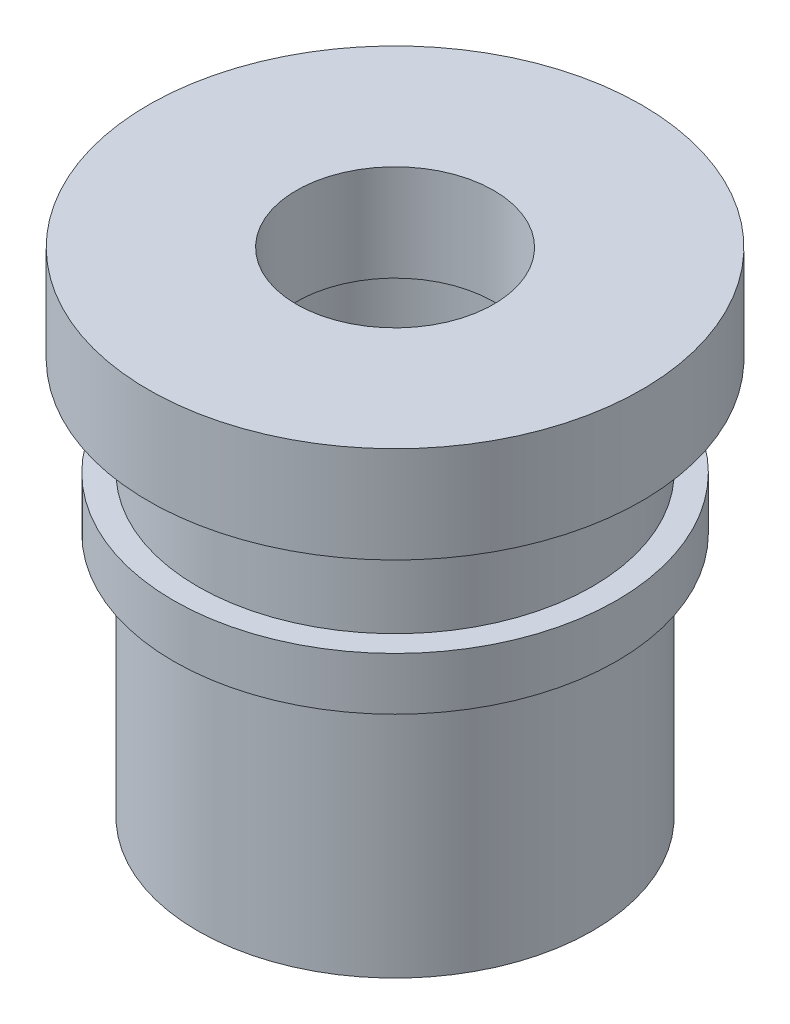
from build123d import *


with BuildPart() as part:
    # Sketch1 → Revolve1 (revolve)
    with BuildSketch(Plane.XY):
        Polygon((1.5875, 7.9375), (3.96875, 7.9375), (3.96875, 6.386464589), (3.175, 6.386464589), (3.175, 4.798964589), (3.564219105, 4.798964589), (3.564219105, 3.95175219), (3.175, 3.95175219), (3.175, 0), (1.897786585, 0), (1.897786585, 6.386464589), (1.5875, 6.386464589), align=None)
    revolve(axis=Axis((0, 0, 0), (0, 1, 0)))


solid = part.part
